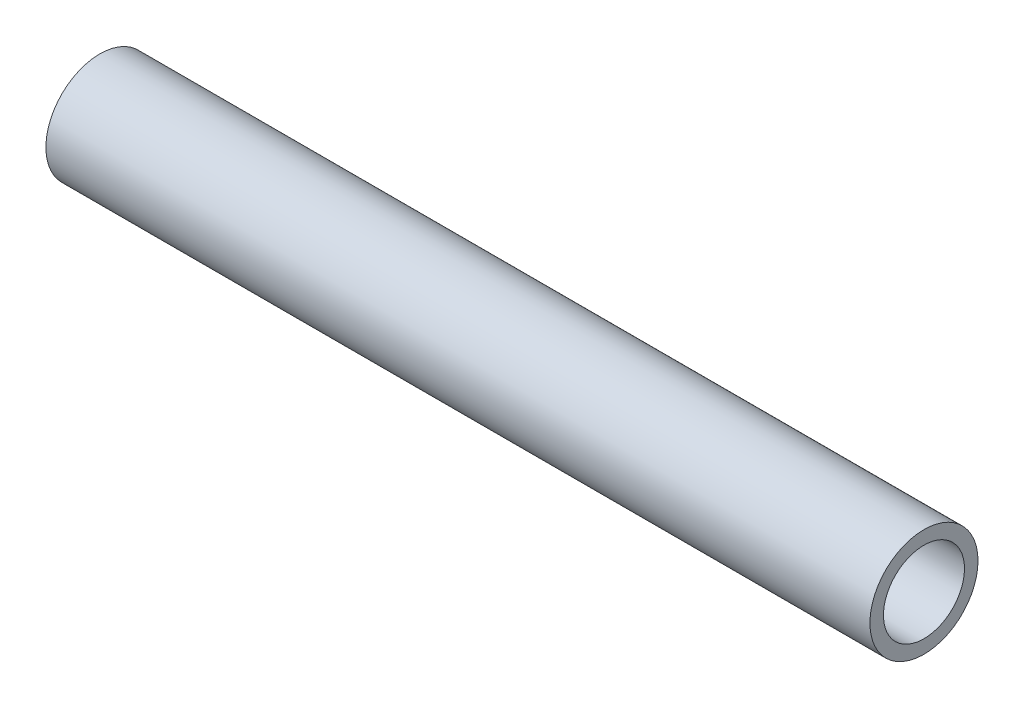
from build123d import *

# Parameters (mm, degrees)
SKETCH1_R           = 12.7
SKETCH1_R_2         = 9.525
BOSS_EXTRUDE1_DEPTH = 193.675


with BuildPart() as part:
    # Sketch1 → Boss-Extrude1 (new body)
    with BuildSketch(Plane(origin=(0, 0, 0), x_dir=(0, 0, -1), z_dir=(1, 0, 0))):
        Circle(SKETCH1_R)
        Circle(SKETCH1_R_2, mode=Mode.SUBTRACT)
    extrude(amount=BOSS_EXTRUDE1_DEPTH)


solid = part.part
